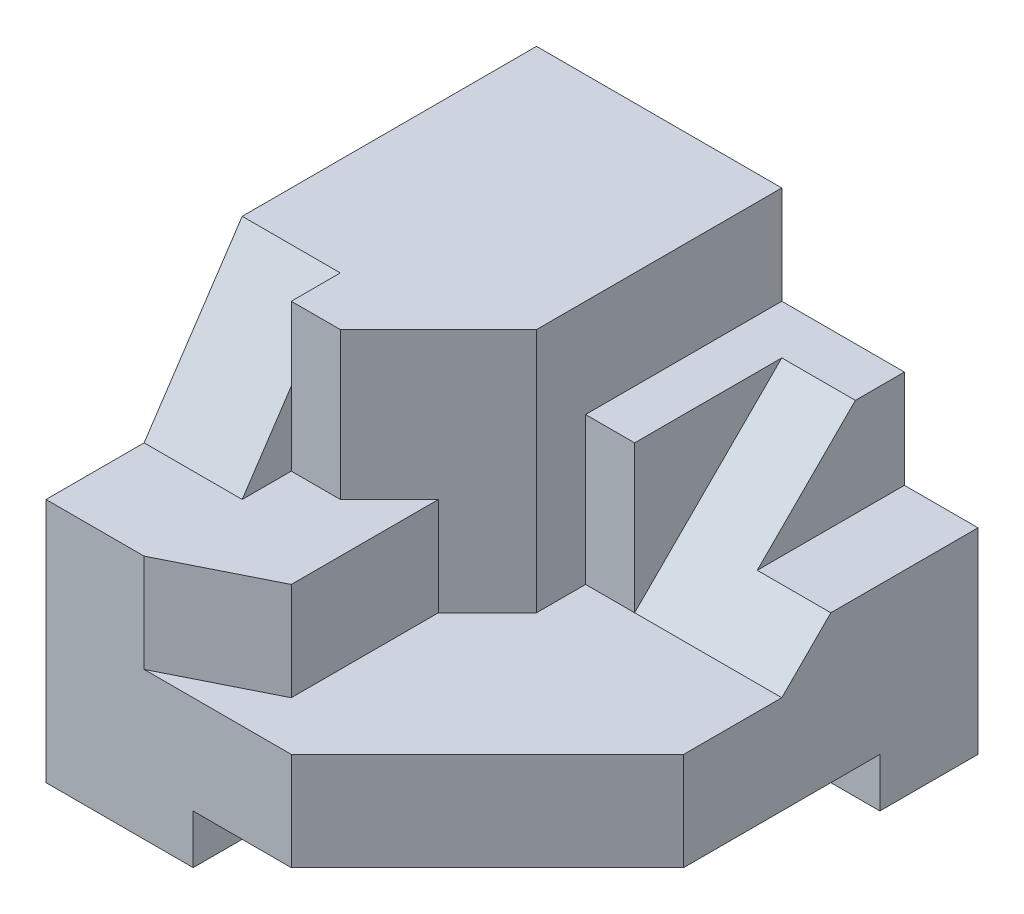
from build123d import *

# Parameters (mm, degrees)
SKETCH1_W           = 9
SKETCH1_H           = 8
BOSS_EXTRUDE1_DEPTH = 10
CUT_EXTRUDE1_DEPTH  = 1.5
CUT_EXTRUDE2_DEPTH  = 1.5
SKETCH6_W           = 6
SKETCH6_H           = 8
CUT_EXTRUDE3_DEPTH  = 1
CUT_EXTRUDE4_DEPTH  = 8
CUT_EXTRUDE5_DEPTH  = 5
CUT_EXTRUDE6_DEPTH  = 1
CUT_EXTRUDE9_DEPTH  = 2
CUT_EXTRUDE10_DEPTH = 3


with BuildPart() as part:
    # Sketch1 → Boss-Extrude1 (new body)
    with BuildSketch(Plane.XY):
        Rectangle(SKETCH1_W, SKETCH1_H)
    extrude(amount=BOSS_EXTRUDE1_DEPTH)

    # Sketch3 → Cut-Extrude1 (cut)
    with BuildSketch(Plane(origin=(4.5, 0, 0), x_dir=(0, 0, -1), z_dir=(1, 0, 0))):
        Polygon((0, 4), (0, 0), (-3, 0), (-4, -1), (-4, 4), align=None)
    extrude(amount=-CUT_EXTRUDE1_DEPTH, mode=Mode.SUBTRACT)

    # Sketch4 → Cut-Extrude2 (cut)
    with BuildSketch(Plane(origin=(3, 0, 0), x_dir=(0, 0, -1), z_dir=(1, 0, 0))):
        Polygon((0, 4), (0, 2), (-1, 2), (-4, -1), (-4, 4), align=None)
    extrude(amount=-CUT_EXTRUDE2_DEPTH, mode=Mode.SUBTRACT)

    # Sketch6 → Cut-Extrude3 (cut)
    with BuildSketch(Plane.XZ.offset(4)):
        with Locations((1.5, 6)):
            Rectangle(SKETCH6_W, SKETCH6_H)
    extrude(amount=-CUT_EXTRUDE3_DEPTH, mode=Mode.SUBTRACT)

    # Sketch7 → Cut-Extrude4 (cut, through all)
    with BuildSketch(Plane(origin=(0, -3, 0), x_dir=(-1, 0, 0), z_dir=(0, -1, 0))):
        Polygon((-0.5, -10), (-4.5, -6), (-4.5, -10), align=None)
    extrude(amount=-CUT_EXTRUDE4_DEPTH, mode=Mode.SUBTRACT)

    # Sketch8 → Cut-Extrude5 (cut)
    with BuildSketch(Plane(origin=(0, 4, 0), x_dir=(1, 0, 0), z_dir=(0, 1, 0))):
        Polygon((4.5, -4), (4.5, -6), (0.5, -10), (-2.5, -10), (-0.5, -9), (-0.5, -6), (0.5, -5), (0.5, -4), (1.5, -4), align=None)
    extrude(amount=-CUT_EXTRUDE5_DEPTH, mode=Mode.SUBTRACT)

    # Sketch9 → Cut-Extrude6 (cut)
    with BuildSketch(Plane(origin=(1.5, 0, 0), x_dir=(0, 0, -1), z_dir=(1, 0, 0))):
        Polygon((-1, 2), (-4, 2), (-4, 4), (0, 4), (0, 2), align=None)
    extrude(amount=-CUT_EXTRUDE6_DEPTH, mode=Mode.SUBTRACT)

    # Sketch10 → Cut-Extrude9 (cut)
    with BuildSketch(Plane.ZY.offset(4.5)):
        Polygon((6, 4), (8, 1), (10, 1), (10, 4), align=None)
    extrude(amount=-CUT_EXTRUDE9_DEPTH, mode=Mode.SUBTRACT)

    # Sketch12 → Cut-Extrude10 (cut)
    with BuildSketch(Plane(origin=(0, 4, 0), x_dir=(1, 0, 0), z_dir=(0, 1, 0))):
        Polygon((0.5, -5), (-1.5, -7), (-2.5, -7), (-2.5, -10), (0.5, -8.5), align=None)
    extrude(amount=-CUT_EXTRUDE10_DEPTH, mode=Mode.SUBTRACT)


solid = part.part
